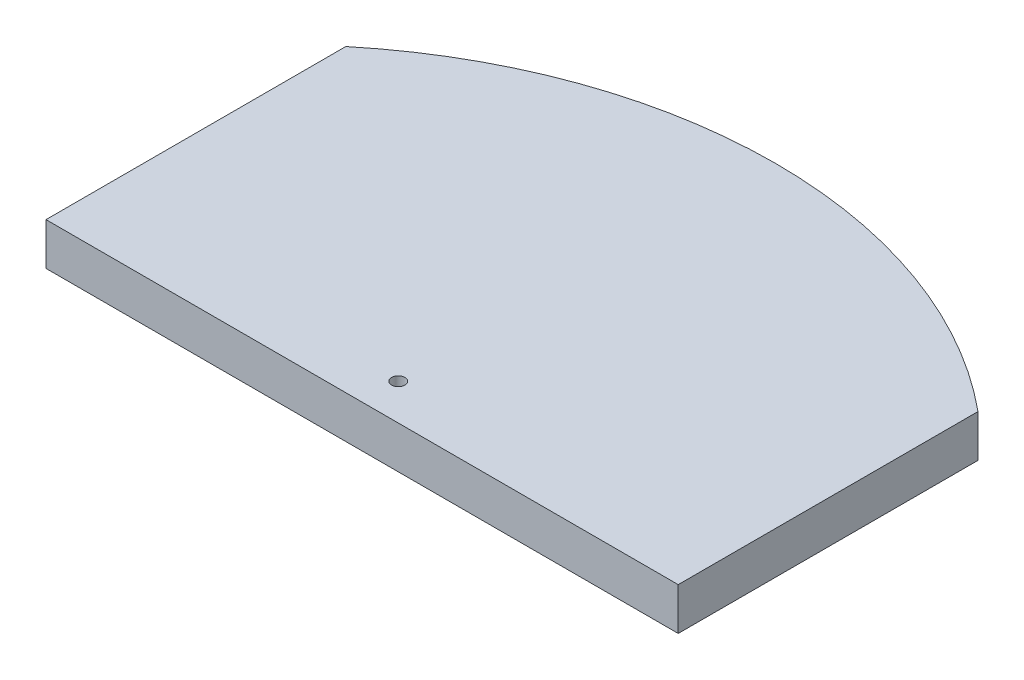
from build123d import *

# Parameters (mm, degrees)
SKETCH1_R           = 1
BOSS_EXTRUDE1_DEPTH = 6.35


with BuildPart() as part:
    # Sketch1 → Boss-Extrude1 (new body)
    with BuildSketch(Plane(origin=(0, 0, 0), x_dir=(1, 0, 0), z_dir=(0, 1, 0))):
        with BuildLine():
            Line((-47.45, -31.685353535), (-47.45, -76.685353535))
            Line((-47.45, -76.685353535), (47.45, -76.685353535))
            Line((47.45, -76.685353535), (47.45, -31.685353535))
            ThreePointArc((47.45, -31.685353535), (0, -14.620077353), (-47.45, -31.685353535))
        make_face()
        with Locations((0, -71.260285785)):
            Circle(SKETCH1_R, mode=Mode.SUBTRACT)
    extrude(amount=BOSS_EXTRUDE1_DEPTH)


solid = part.part
